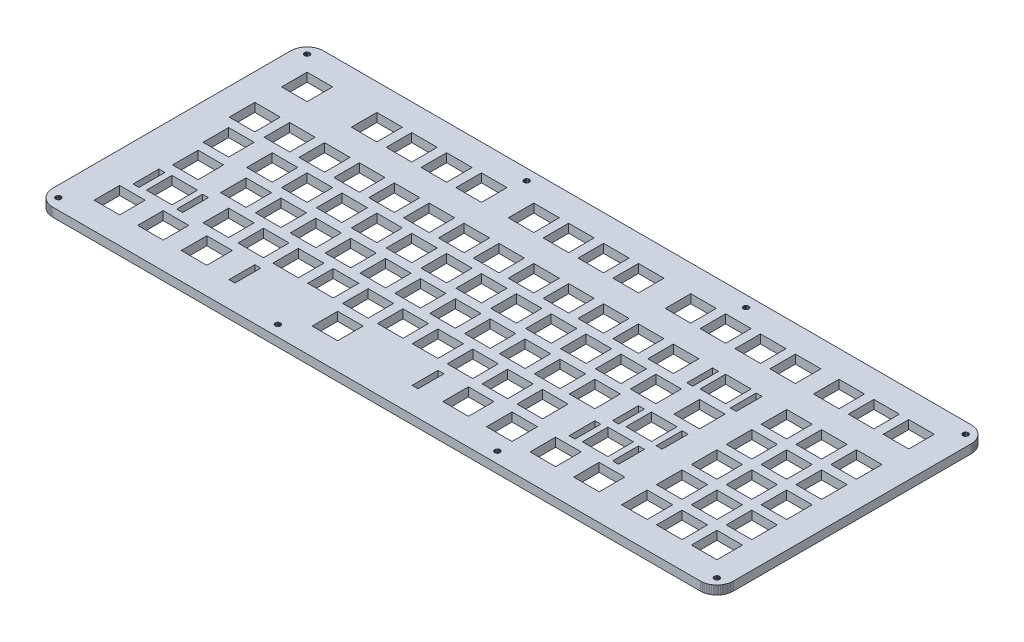
from build123d import *

# Parameters (mm, degrees)
SKETCH1_W           = 3.2494
SKETCH1_H           = 14.1497
SKETCH1_W_2         = 3.25
SKETCH1_W_3         = 13.9498
SKETCH1_H_2         = 13.9499
SKETCH1_W_4         = 13.95
SKETCH1_W_5         = 13.951
SKETCH1_W_6         = 3.2495
SKETCH1_H_3         = 14.1484
SKETCH1_W_7         = 3.249
SKETCH1_W_8         = 13.9499
SKETCH1_W_9         = 13.9503
SKETCH1_H_4         = 14.1485
SKETCH1_H_5         = 14.1503
SKETCH1_W_10        = 3.251
SKETCH1_H_6         = 13.9502
SKETCH1_H_7         = 13.95
BOSS_EXTRUDE1_DEPTH = 4.7625


with BuildPart() as part:
    # Sketch1 → Boss-Extrude1 (new body)
    with BuildSketch(Plane(origin=(0, 0, 0), x_dir=(1, 0, 0), z_dir=(0, 1, 0))):
        Polygon((362.807, 147.967), (363.513, 147.941), (364.215, 147.857), (364.91, 147.719), (365.591, 147.527), (366.254, 147.282), (366.896, 146.987), (367.51, 146.641), (368.099, 146.25), (368.653, 145.812), (369.171, 145.331), (369.651, 144.812), (370.089, 144.259), (370.48, 143.67), (370.826, 143.053), (371.122, 142.412), (371.369, 141.749), (371.56, 141.07), (371.697, 140.375), (371.778, 139.674), (371.807, 138.967), (371.807, 9.09091), (371.778, 8.38535), (371.697, 7.68396), (371.56, 6.99079), (371.369, 6.31003), (371.122, 5.6472), (370.826, 5.00641), (370.48, 4.38905), (370.089, 3.80062), (369.651, 3.24666), (369.171, 2.72852), (368.653, 2.24758), (368.099, 1.81074), (367.51, 1.418), (366.896, 1.07211), (366.254, 0.777215), (365.591, 0.531922), (364.91, 0.340376), (364.215, 0.202572), (363.513, 0.118511), (362.807, 0.0909507), (9.09507, 0.0909507), (8.3881, 0.118511), (7.68671, 0.202572), (6.99216, 0.340376), (6.31278, 0.531922), (5.64995, 0.777215), (5.00916, 1.07211), (4.3918, 1.418), (3.8034, 1.81074), (3.24942, 2.24758), (2.73127, 2.72852), (2.25034, 3.24666), (1.81212, 3.80062), (1.42076, 4.38905), (1.07487, 5.00641), (0.77997, 5.6472), (0.534681, 6.31003), (0.343131, 6.99079), (0.205328, 7.68396), (0.121267, 8.38535), (0.0937066, 9.09228), (0.0950846, 138.967), (0.121267, 139.674), (0.205328, 140.375), (0.343131, 141.07), (0.534681, 141.749), (0.77997, 142.412), (1.07487, 143.053), (1.42076, 143.67), (1.81212, 144.259), (2.25034, 144.812), (2.73127, 145.331), (3.24942, 145.812), (3.8034, 146.25), (4.3918, 146.641), (5.00916, 146.987), (5.64995, 147.282), (6.31278, 147.527), (6.99216, 147.719), (7.68671, 147.857), (8.3881, 147.941), (9.09507, 147.968), align=None)
        Polygon((365.326, 7.51858), (364.917, 7.31188), (364.589, 6.98253), (364.381, 6.57186), (364.307, 6.11572), (364.381, 5.66099), (364.589, 5.25032), (364.917, 4.92372), (365.326, 4.71428), (365.781, 4.64125), (366.24, 4.71428), (366.649, 4.92372), (366.977, 5.25032), (367.185, 5.66099), (367.259, 6.11572), (367.185, 6.57186), (366.977, 6.98253), (366.649, 7.31188), (366.24, 7.51858), (365.781, 7.5916), align=None, mode=Mode.SUBTRACT)
        Polygon((245.438, 7.51858), (245.027, 7.31188), (244.703, 6.98253), (244.492, 6.57186), (244.42, 6.11572), (244.492, 5.66099), (244.703, 5.25032), (245.027, 4.92372), (245.438, 4.71428), (245.894, 4.64125), (246.35, 4.71428), (246.761, 4.92372), (247.088, 5.25032), (247.297, 5.66099), (247.37, 6.11572), (247.297, 6.57186), (247.088, 6.98253), (246.761, 7.31188), (246.35, 7.51858), (245.894, 7.5916), align=None, mode=Mode.SUBTRACT)
        Polygon((125.552, 7.51858), (125.138, 7.31188), (124.815, 6.98253), (124.604, 6.57186), (124.532, 6.11572), (124.604, 5.66099), (124.815, 5.25032), (125.138, 4.92372), (125.552, 4.71428), (126.007, 4.64125), (126.463, 4.71428), (126.873, 4.92372), (127.201, 5.25032), (127.409, 5.66099), (127.482, 6.11572), (127.409, 6.57186), (127.201, 6.98253), (126.873, 7.31188), (126.463, 7.51858), (126.007, 7.5916), align=None, mode=Mode.SUBTRACT)
        Polygon((5.66374, 7.51858), (5.25307, 7.31188), (4.9251, 6.98253), (4.71703, 6.57186), (4.644, 6.11572), (4.71703, 5.66099), (4.9251, 5.25032), (5.25307, 4.92372), (5.66374, 4.71428), (6.11851, 4.64125), (6.57461, 4.71428), (6.98528, 4.92372), (7.31326, 5.25032), (7.52133, 5.66099), (7.59435, 6.11572), (7.52133, 6.57186), (7.31326, 6.98253), (6.98528, 7.31188), (6.57461, 7.51858), (6.11851, 7.5916), align=None, mode=Mode.SUBTRACT)
        with Locations((93.088, 20.99305)):
            Rectangle(SKETCH1_W, SKETCH1_H, mode=Mode.SUBTRACT)
        with Locations((193.088, 20.99305)):
            Rectangle(SKETCH1_W_2, SKETCH1_H, mode=Mode.SUBTRACT)
        with Locations((24.0254, 21.64275)):
            Rectangle(SKETCH1_W_3, SKETCH1_H_2, mode=Mode.SUBTRACT)
        with Locations((47.8379, 21.64275)):
            Rectangle(SKETCH1_W_3, SKETCH1_H_2, mode=Mode.SUBTRACT)
        with Locations((71.6504, 21.64275)):
            Rectangle(SKETCH1_W_3, SKETCH1_H_2, mode=Mode.SUBTRACT)
        with Locations((143.088, 21.64275)):
            Rectangle(SKETCH1_W_4, SKETCH1_H_2, mode=Mode.SUBTRACT)
        with Locations((214.525, 21.64275)):
            Rectangle(SKETCH1_W_4, SKETCH1_H_2, mode=Mode.SUBTRACT)
        with Locations((238.338, 21.64275)):
            Rectangle(SKETCH1_W_4, SKETCH1_H_2, mode=Mode.SUBTRACT)
        with Locations((262.15, 21.64275)):
            Rectangle(SKETCH1_W_4, SKETCH1_H_2, mode=Mode.SUBTRACT)
        with Locations((285.963, 21.64275)):
            Rectangle(SKETCH1_W_4, SKETCH1_H_2, mode=Mode.SUBTRACT)
        with Locations((312.157, 21.64275)):
            Rectangle(SKETCH1_W_4, SKETCH1_H_2, mode=Mode.SUBTRACT)
        with Locations((331.207, 21.64275)):
            Rectangle(SKETCH1_W_4, SKETCH1_H_2, mode=Mode.SUBTRACT)
        with Locations((350.2575, 21.64275)):
            Rectangle(SKETCH1_W_5, SKETCH1_H_2, mode=Mode.SUBTRACT)
        with Locations((21.65035, 40.0424)):
            Rectangle(SKETCH1_W_6, SKETCH1_H_3, mode=Mode.SUBTRACT)
        with Locations((45.4503, 40.0424)):
            Rectangle(SKETCH1_W, SKETCH1_H_3, mode=Mode.SUBTRACT)
        with Locations((259.7755, 40.0424)):
            Rectangle(SKETCH1_W_7, SKETCH1_H_3, mode=Mode.SUBTRACT)
        with Locations((283.5755, 40.0424)):
            Rectangle(SKETCH1_W_7, SKETCH1_H_3, mode=Mode.SUBTRACT)
        with Locations((33.5504, 40.69275)):
            Rectangle(SKETCH1_W_3, SKETCH1_H_2, mode=Mode.SUBTRACT)
        with Locations((64.50665, 40.69275)):
            Rectangle(SKETCH1_W_8, SKETCH1_H_2, mode=Mode.SUBTRACT)
        with Locations((83.55665, 40.69275)):
            Rectangle(SKETCH1_W_8, SKETCH1_H_2, mode=Mode.SUBTRACT)
        with Locations((102.60685, 40.69275)):
            Rectangle(SKETCH1_W_9, SKETCH1_H_2, mode=Mode.SUBTRACT)
        with Locations((121.657, 40.69275)):
            Rectangle(SKETCH1_W_4, SKETCH1_H_2, mode=Mode.SUBTRACT)
        with Locations((140.707, 40.69275)):
            Rectangle(SKETCH1_W_4, SKETCH1_H_2, mode=Mode.SUBTRACT)
        with Locations((159.757, 40.69275)):
            Rectangle(SKETCH1_W_4, SKETCH1_H_2, mode=Mode.SUBTRACT)
        with Locations((178.807, 40.69275)):
            Rectangle(SKETCH1_W_4, SKETCH1_H_2, mode=Mode.SUBTRACT)
        with Locations((197.857, 40.69275)):
            Rectangle(SKETCH1_W_4, SKETCH1_H_2, mode=Mode.SUBTRACT)
        with Locations((216.907, 40.69275)):
            Rectangle(SKETCH1_W_4, SKETCH1_H_2, mode=Mode.SUBTRACT)
        with Locations((235.957, 40.69275)):
            Rectangle(SKETCH1_W_4, SKETCH1_H_2, mode=Mode.SUBTRACT)
        with Locations((271.675, 40.69275)):
            Rectangle(SKETCH1_W_4, SKETCH1_H_2, mode=Mode.SUBTRACT)
        with Locations((312.157, 40.69275)):
            Rectangle(SKETCH1_W_4, SKETCH1_H_2, mode=Mode.SUBTRACT)
        with Locations((331.207, 40.69275)):
            Rectangle(SKETCH1_W_4, SKETCH1_H_2, mode=Mode.SUBTRACT)
        with Locations((350.2575, 40.69275)):
            Rectangle(SKETCH1_W_5, SKETCH1_H_2, mode=Mode.SUBTRACT)
        with Locations((264.538, 59.09235)):
            Rectangle(SKETCH1_W_2, SKETCH1_H_4, mode=Mode.SUBTRACT)
        with Locations((288.338, 59.09235)):
            Rectangle(SKETCH1_W_2, SKETCH1_H_4, mode=Mode.SUBTRACT)
        with Locations((28.7879, 59.74275)):
            Rectangle(SKETCH1_W_3, SKETCH1_H_2, mode=Mode.SUBTRACT)
        with Locations((54.98165, 59.74275)):
            Rectangle(SKETCH1_W_8, SKETCH1_H_2, mode=Mode.SUBTRACT)
        with Locations((74.03165, 59.74275)):
            Rectangle(SKETCH1_W_8, SKETCH1_H_2, mode=Mode.SUBTRACT)
        with Locations((93.08185, 59.74275)):
            Rectangle(SKETCH1_W_9, SKETCH1_H_2, mode=Mode.SUBTRACT)
        with Locations((112.132, 59.74275)):
            Rectangle(SKETCH1_W_4, SKETCH1_H_2, mode=Mode.SUBTRACT)
        with Locations((131.182, 59.74275)):
            Rectangle(SKETCH1_W_4, SKETCH1_H_2, mode=Mode.SUBTRACT)
        with Locations((150.232, 59.74275)):
            Rectangle(SKETCH1_W_4, SKETCH1_H_2, mode=Mode.SUBTRACT)
        with Locations((169.282, 59.74275)):
            Rectangle(SKETCH1_W_4, SKETCH1_H_2, mode=Mode.SUBTRACT)
        with Locations((188.332, 59.74275)):
            Rectangle(SKETCH1_W_4, SKETCH1_H_2, mode=Mode.SUBTRACT)
        with Locations((207.382, 59.74275)):
            Rectangle(SKETCH1_W_4, SKETCH1_H_2, mode=Mode.SUBTRACT)
        with Locations((226.432, 59.74275)):
            Rectangle(SKETCH1_W_4, SKETCH1_H_2, mode=Mode.SUBTRACT)
        with Locations((245.482, 59.74275)):
            Rectangle(SKETCH1_W_4, SKETCH1_H_2, mode=Mode.SUBTRACT)
        with Locations((276.438, 59.74275)):
            Rectangle(SKETCH1_W_4, SKETCH1_H_2, mode=Mode.SUBTRACT)
        with Locations((312.157, 59.74275)):
            Rectangle(SKETCH1_W_4, SKETCH1_H_2, mode=Mode.SUBTRACT)
        with Locations((331.207, 59.74275)):
            Rectangle(SKETCH1_W_4, SKETCH1_H_2, mode=Mode.SUBTRACT)
        with Locations((350.2575, 59.74275)):
            Rectangle(SKETCH1_W_5, SKETCH1_H_2, mode=Mode.SUBTRACT)
        with Locations((26.40665, 78.79275)):
            Rectangle(SKETCH1_W_8, SKETCH1_H_2, mode=Mode.SUBTRACT)
        with Locations((50.21915, 78.79275)):
            Rectangle(SKETCH1_W_8, SKETCH1_H_2, mode=Mode.SUBTRACT)
        with Locations((69.26915, 78.79275)):
            Rectangle(SKETCH1_W_8, SKETCH1_H_2, mode=Mode.SUBTRACT)
        with Locations((88.31915, 78.79275)):
            Rectangle(SKETCH1_W_8, SKETCH1_H_2, mode=Mode.SUBTRACT)
        with Locations((107.369, 78.79275)):
            Rectangle(SKETCH1_W_4, SKETCH1_H_2, mode=Mode.SUBTRACT)
        with Locations((126.419, 78.79275)):
            Rectangle(SKETCH1_W_4, SKETCH1_H_2, mode=Mode.SUBTRACT)
        with Locations((145.469, 78.79275)):
            Rectangle(SKETCH1_W_4, SKETCH1_H_2, mode=Mode.SUBTRACT)
        with Locations((164.519, 78.79275)):
            Rectangle(SKETCH1_W_4, SKETCH1_H_2, mode=Mode.SUBTRACT)
        with Locations((183.569, 78.79275)):
            Rectangle(SKETCH1_W_4, SKETCH1_H_2, mode=Mode.SUBTRACT)
        with Locations((202.619, 78.79275)):
            Rectangle(SKETCH1_W_4, SKETCH1_H_2, mode=Mode.SUBTRACT)
        with Locations((221.669, 78.79275)):
            Rectangle(SKETCH1_W_4, SKETCH1_H_2, mode=Mode.SUBTRACT)
        with Locations((240.719, 78.79275)):
            Rectangle(SKETCH1_W_4, SKETCH1_H_2, mode=Mode.SUBTRACT)
        with Locations((259.769, 78.79275)):
            Rectangle(SKETCH1_W_4, SKETCH1_H_2, mode=Mode.SUBTRACT)
        with Locations((283.582, 78.79275)):
            Rectangle(SKETCH1_W_4, SKETCH1_H_2, mode=Mode.SUBTRACT)
        with Locations((312.157, 78.79275)):
            Rectangle(SKETCH1_W_4, SKETCH1_H_2, mode=Mode.SUBTRACT)
        with Locations((331.207, 78.79275)):
            Rectangle(SKETCH1_W_4, SKETCH1_H_2, mode=Mode.SUBTRACT)
        with Locations((350.2575, 78.79275)):
            Rectangle(SKETCH1_W_5, SKETCH1_H_2, mode=Mode.SUBTRACT)
        with Locations((266.92, 97.19185)):
            Rectangle(SKETCH1_W_2, SKETCH1_H_5, mode=Mode.SUBTRACT)
        with Locations((290.7195, 97.19185)):
            Rectangle(SKETCH1_W_10, SKETCH1_H_5, mode=Mode.SUBTRACT)
        with Locations((21.64415, 97.8429)):
            Rectangle(SKETCH1_W_8, SKETCH1_H_6, mode=Mode.SUBTRACT)
        with Locations((40.69415, 97.8429)):
            Rectangle(SKETCH1_W_8, SKETCH1_H_6, mode=Mode.SUBTRACT)
        with Locations((59.74415, 97.8429)):
            Rectangle(SKETCH1_W_8, SKETCH1_H_6, mode=Mode.SUBTRACT)
        with Locations((78.79415, 97.8429)):
            Rectangle(SKETCH1_W_8, SKETCH1_H_6, mode=Mode.SUBTRACT)
        with Locations((97.8441, 97.8429)):
            Rectangle(SKETCH1_W_3, SKETCH1_H_6, mode=Mode.SUBTRACT)
        with Locations((116.894, 97.8429)):
            Rectangle(SKETCH1_W_4, SKETCH1_H_6, mode=Mode.SUBTRACT)
        with Locations((135.944, 97.8429)):
            Rectangle(SKETCH1_W_4, SKETCH1_H_6, mode=Mode.SUBTRACT)
        with Locations((154.994, 97.8429)):
            Rectangle(SKETCH1_W_4, SKETCH1_H_6, mode=Mode.SUBTRACT)
        with Locations((174.044, 97.8429)):
            Rectangle(SKETCH1_W_4, SKETCH1_H_6, mode=Mode.SUBTRACT)
        with Locations((193.094, 97.8429)):
            Rectangle(SKETCH1_W_4, SKETCH1_H_6, mode=Mode.SUBTRACT)
        with Locations((212.144, 97.8429)):
            Rectangle(SKETCH1_W_4, SKETCH1_H_6, mode=Mode.SUBTRACT)
        with Locations((231.194, 97.8429)):
            Rectangle(SKETCH1_W_4, SKETCH1_H_6, mode=Mode.SUBTRACT)
        with Locations((250.244, 97.8429)):
            Rectangle(SKETCH1_W_4, SKETCH1_H_6, mode=Mode.SUBTRACT)
        with Locations((278.819, 97.8429)):
            Rectangle(SKETCH1_W_4, SKETCH1_H_6, mode=Mode.SUBTRACT)
        with Locations((312.157, 97.8429)):
            Rectangle(SKETCH1_W_4, SKETCH1_H_6, mode=Mode.SUBTRACT)
        with Locations((331.207, 97.8429)):
            Rectangle(SKETCH1_W_4, SKETCH1_H_6, mode=Mode.SUBTRACT)
        with Locations((350.2575, 97.8429)):
            Rectangle(SKETCH1_W_5, SKETCH1_H_6, mode=Mode.SUBTRACT)
        with Locations((21.64415, 126.418)):
            Rectangle(SKETCH1_W_8, SKETCH1_H_7, mode=Mode.SUBTRACT)
        with Locations((59.74415, 126.418)):
            Rectangle(SKETCH1_W_8, SKETCH1_H_7, mode=Mode.SUBTRACT)
        with Locations((78.79415, 126.418)):
            Rectangle(SKETCH1_W_8, SKETCH1_H_7, mode=Mode.SUBTRACT)
        with Locations((97.8441, 126.418)):
            Rectangle(SKETCH1_W_3, SKETCH1_H_7, mode=Mode.SUBTRACT)
        with Locations((116.894, 126.418)):
            Rectangle(SKETCH1_W_4, SKETCH1_H_7, mode=Mode.SUBTRACT)
        with Locations((145.469, 126.418)):
            Rectangle(SKETCH1_W_4, SKETCH1_H_7, mode=Mode.SUBTRACT)
        with Locations((164.519, 126.418)):
            Rectangle(SKETCH1_W_4, SKETCH1_H_7, mode=Mode.SUBTRACT)
        with Locations((183.569, 126.418)):
            Rectangle(SKETCH1_W_4, SKETCH1_H_7, mode=Mode.SUBTRACT)
        with Locations((202.619, 126.418)):
            Rectangle(SKETCH1_W_4, SKETCH1_H_7, mode=Mode.SUBTRACT)
        with Locations((231.194, 126.418)):
            Rectangle(SKETCH1_W_4, SKETCH1_H_7, mode=Mode.SUBTRACT)
        with Locations((250.244, 126.418)):
            Rectangle(SKETCH1_W_4, SKETCH1_H_7, mode=Mode.SUBTRACT)
        with Locations((269.294, 126.418)):
            Rectangle(SKETCH1_W_4, SKETCH1_H_7, mode=Mode.SUBTRACT)
        with Locations((288.344, 126.418)):
            Rectangle(SKETCH1_W_4, SKETCH1_H_7, mode=Mode.SUBTRACT)
        with Locations((312.157, 126.418)):
            Rectangle(SKETCH1_W_4, SKETCH1_H_7, mode=Mode.SUBTRACT)
        with Locations((331.207, 126.418)):
            Rectangle(SKETCH1_W_4, SKETCH1_H_7, mode=Mode.SUBTRACT)
        with Locations((350.2575, 126.418)):
            Rectangle(SKETCH1_W_5, SKETCH1_H_7, mode=Mode.SUBTRACT)
        Polygon((125.552, 143.345), (125.138, 143.137), (124.815, 142.809), (124.604, 142.398), (124.532, 141.942), (124.604, 141.487), (124.815, 141.077), (125.138, 140.75), (125.552, 140.541), (126.007, 140.468), (126.463, 140.541), (126.873, 140.75), (127.201, 141.077), (127.409, 141.487), (127.482, 141.942), (127.409, 142.398), (127.201, 142.809), (126.873, 143.137), (126.463, 143.345), (126.007, 143.417), align=None, mode=Mode.SUBTRACT)
        Polygon((245.438, 143.345), (245.027, 143.137), (244.703, 142.809), (244.492, 142.398), (244.42, 141.942), (244.492, 141.487), (244.703, 141.077), (245.027, 140.75), (245.438, 140.541), (245.894, 140.468), (246.35, 140.541), (246.761, 140.75), (247.088, 141.077), (247.297, 141.487), (247.37, 141.942), (247.297, 142.398), (247.088, 142.809), (246.761, 143.137), (246.35, 143.345), (245.894, 143.417), align=None, mode=Mode.SUBTRACT)
        Polygon((365.326, 143.345), (364.917, 143.137), (364.589, 142.809), (364.381, 142.398), (364.307, 141.942), (364.381, 141.487), (364.589, 141.077), (364.917, 140.75), (365.326, 140.541), (365.781, 140.468), (366.24, 140.541), (366.649, 140.75), (366.977, 141.077), (367.185, 141.487), (367.259, 141.942), (367.185, 142.398), (366.977, 142.809), (366.649, 143.137), (366.24, 143.345), (365.781, 143.417), align=None, mode=Mode.SUBTRACT)
        Polygon((5.66374, 143.345), (5.25307, 143.137), (4.9251, 142.809), (4.71703, 142.398), (4.644, 141.942), (4.71703, 141.487), (4.9251, 141.077), (5.25307, 140.75), (5.66374, 140.541), (6.11851, 140.468), (6.57461, 140.541), (6.98528, 140.75), (7.31326, 141.077), (7.52133, 141.487), (7.59435, 141.942), (7.52133, 142.398), (7.31326, 142.809), (6.98528, 143.137), (6.57461, 143.345), (6.11851, 143.417), align=None, mode=Mode.SUBTRACT)
    extrude(amount=BOSS_EXTRUDE1_DEPTH)


solid = part.part
